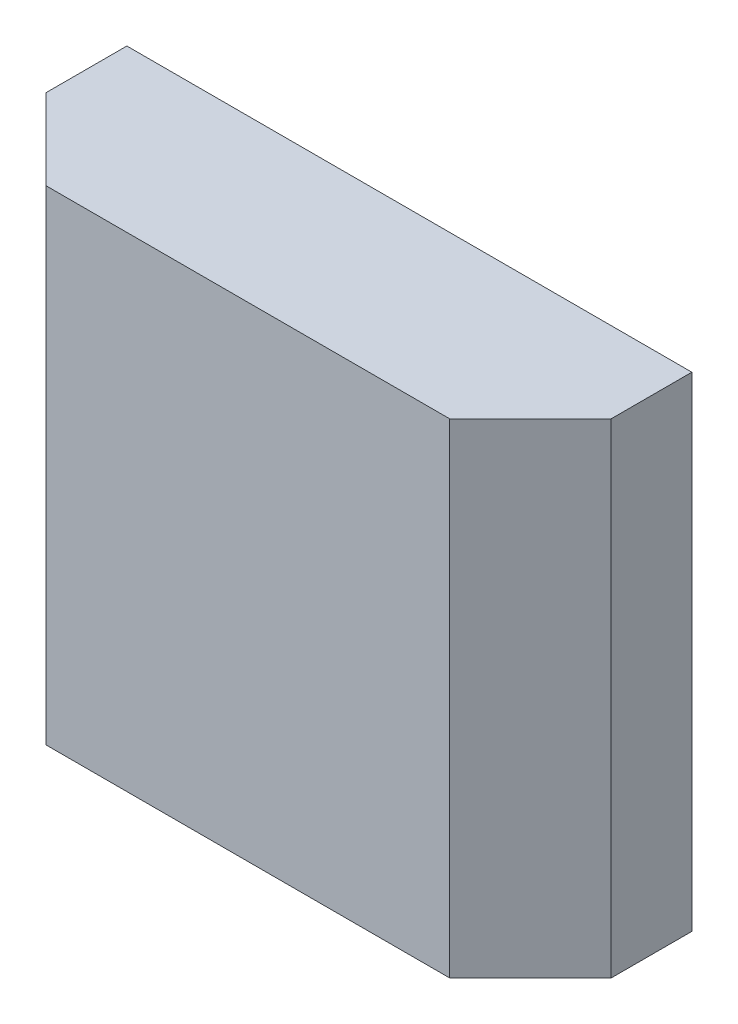
from build123d import *

# Parameters (mm, degrees)
BOSS_EXTRUDE1_DEPTH = 6


with BuildPart() as part:
    # Sketch1 → Boss-Extrude1 (new body)
    with BuildSketch(Plane(origin=(0, 0, 0), x_dir=(1, 0, 0), z_dir=(0, 1, 0))):
        Polygon((-3.5, 1), (3.5, 1), (3.5, 0), (2.5, -1), (-2.5, -1), (-3.5, 0), align=None)
    extrude(amount=BOSS_EXTRUDE1_DEPTH)


solid = part.part
